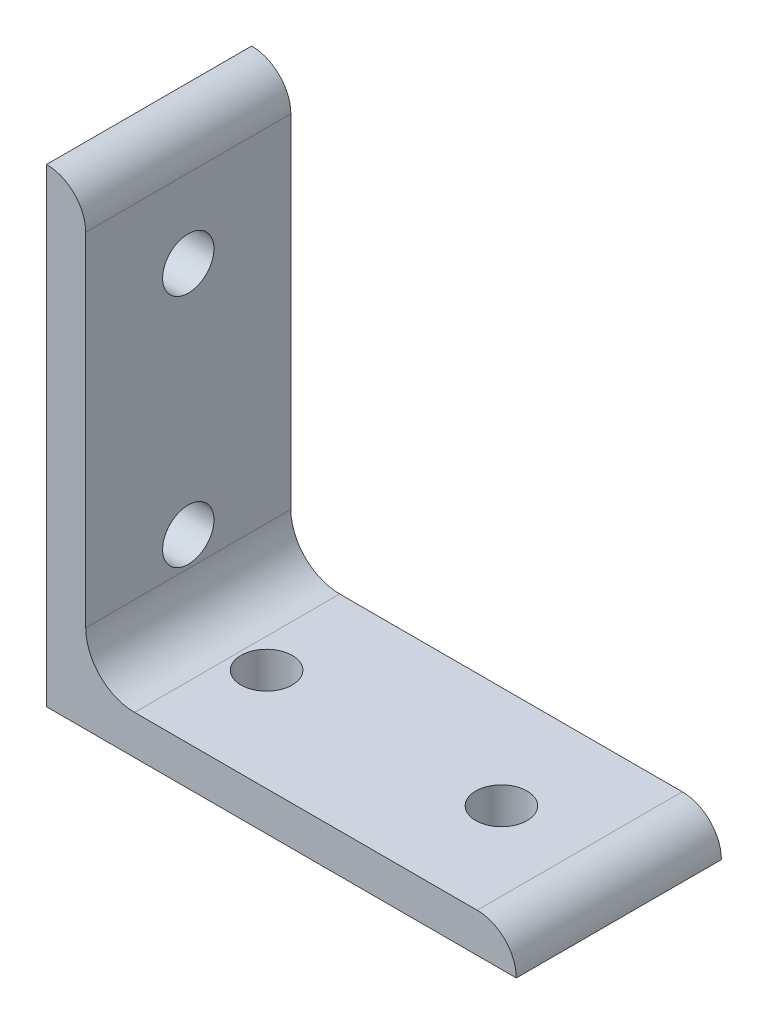
from build123d import *

# Parameters (mm, degrees)
BOSS_EXTRUDE1_DEPTH = 16.637
SKETCH2_R           = 4.1656
CUT_EXTRUDE1_DEPTH  = 77.2
SKETCH3_R           = 4.1656
CUT_EXTRUDE2_DEPTH  = 77.2


with BuildPart() as part:
    # Sketch1 → Boss-Extrude1 (new body, symmetric)
    with BuildSketch(Plane.XY):
        with BuildLine():
            Line((0, 0), (0, 76.2))
            ThreePointArc((0, 76.2), (4.490128061, 74.340128061), (6.35, 69.85))
            Line((6.35, 69.85), (6.35, 14.2748))
            ThreePointArc((6.35, 14.2748), (8.67112018, 8.67112018), (14.2748, 6.35))
            Line((14.2748, 6.35), (69.85, 6.35))
            ThreePointArc((69.85, 6.35), (74.340128061, 4.490128061), (76.2, 0))
            Line((76.2, 0), (0, 0))
        make_face()
    extrude(amount=BOSS_EXTRUDE1_DEPTH, both=True)

    # Sketch2 → Cut-Extrude1 (cut, through all)
    with BuildSketch(Plane(origin=(0, 0, 0), x_dir=(1, 0, 0), z_dir=(0, 1, 0))):
        with Locations((19.05, 0)):
            Circle(SKETCH2_R)
        with Locations((57.15, 0)):
            Circle(SKETCH2_R)
    extrude(amount=CUT_EXTRUDE1_DEPTH, mode=Mode.SUBTRACT)

    # Sketch3 → Cut-Extrude2 (cut, through all)
    with BuildSketch(Plane(origin=(0, 0, 0), x_dir=(0, 0, -1), z_dir=(1, 0, 0))):
        with Locations((0, 19.05)):
            Circle(SKETCH3_R)
        with Locations((0, 57.15)):
            Circle(SKETCH3_R)
    extrude(amount=CUT_EXTRUDE2_DEPTH, mode=Mode.SUBTRACT)


solid = part.part
